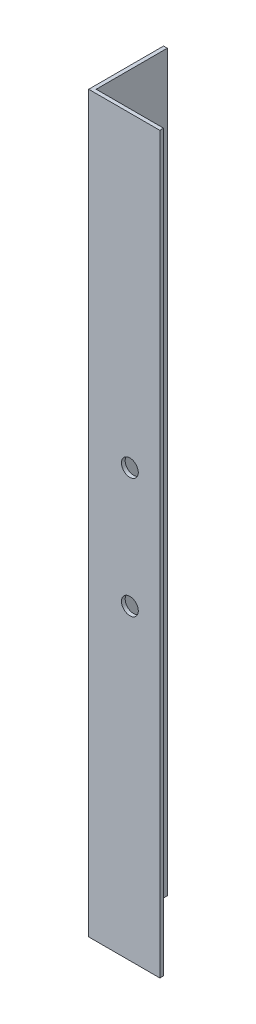
from build123d import *

# Parameters (mm, degrees)
EXTRUDE_1_DEPTH     = 196
SKETCH_2_W          = 1
SKETCH_2_H          = 196
CUT_EXTRUDE_1_DEPTH = 1
SKETCH1_R           = 2.25
CUT_EXTRUDE1_DEPTH  = 2


with BuildPart() as part:
    # Эскиз1 → Бобышка-Вытянуть1 (new body)
    with BuildSketch(Plane(origin=(0, 0, 0), x_dir=(1, 0, 0), z_dir=(0, 1, 0))):
        Polygon((0, 0), (0, 20), (1, 20), (1, 1), (20, 1), (20, 0), align=None)
    extrude(amount=EXTRUDE_1_DEPTH)

    # Эскиз2 → Вырез-Вытянуть1 (cut)
    with BuildSketch(Plane(origin=(20, 0, 0), x_dir=(0, 0, -1), z_dir=(1, 0, 0))):
        with Locations((0.5, 98)):
            Rectangle(SKETCH_2_W, SKETCH_2_H)
    extrude(amount=-CUT_EXTRUDE_1_DEPTH, mode=Mode.SUBTRACT)

    # Sketch1 → Cut-Extrude1 (cut, through all)
    with BuildSketch(Plane(origin=(0, 0, -1), x_dir=(-1, 0, 0), z_dir=(0, 0, -1))):
        with Locations((-11, 82)):
            Circle(SKETCH1_R)
        with Locations((-11, 114)):
            Circle(SKETCH1_R)
    extrude(amount=-CUT_EXTRUDE1_DEPTH, mode=Mode.SUBTRACT)


solid = part.part
